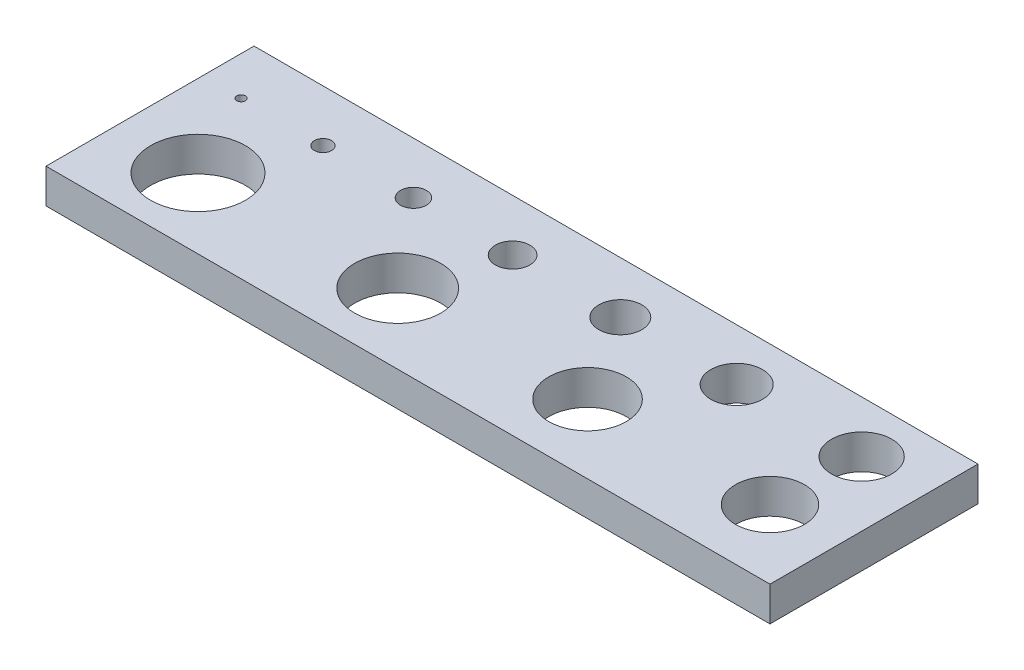
from build123d import *

# Parameters (mm, degrees)
SKETCH1_W           = 210
SKETCH1_H           = 60.3421622
SKETCH1_R           = 1.25
SKETCH1_R_2         = 2.5
SKETCH1_R_3         = 3.75
SKETCH1_R_4         = 5
SKETCH1_R_5         = 6.25
SKETCH1_R_6         = 7.5
SKETCH1_R_7         = 8.75
SKETCH1_R_8         = 10
SKETCH1_R_9         = 11.25
SKETCH1_R_10        = 12.5
SKETCH1_R_11        = 13.75
BOSS_EXTRUDE1_DEPTH = 10


with BuildPart() as part:
    # Sketch1 → Boss-Extrude1 (new body)
    with BuildSketch(Plane(origin=(0, 0, 0), x_dir=(1, 0, 0), z_dir=(0, 1, 0))):
        with Locations((93.75, -15.1710811)):
            Rectangle(SKETCH1_W, SKETCH1_H)
        Circle(SKETCH1_R, mode=Mode.SUBTRACT)
        with Locations((23.75, 0)):
            Circle(SKETCH1_R_2, mode=Mode.SUBTRACT)
        with Locations((50, 0)):
            Circle(SKETCH1_R_3, mode=Mode.SUBTRACT)
        with Locations((78.75, 0)):
            Circle(SKETCH1_R_4, mode=Mode.SUBTRACT)
        with Locations((110, 0)):
            Circle(SKETCH1_R_5, mode=Mode.SUBTRACT)
        with Locations((143.75, 0)):
            Circle(SKETCH1_R_6, mode=Mode.SUBTRACT)
        with Locations((180, 0)):
            Circle(SKETCH1_R_7, mode=Mode.SUBTRACT)
        with Locations((178.75, -25.3421622)):
            Circle(SKETCH1_R_8, mode=Mode.SUBTRACT)
        with Locations((125.831772041, -25.3421622)):
            Circle(SKETCH1_R_9, mode=Mode.SUBTRACT)
        with Locations((70.418227959, -25)):
            Circle(SKETCH1_R_10, mode=Mode.SUBTRACT)
        with Locations((12.5, -25)):
            Circle(SKETCH1_R_11, mode=Mode.SUBTRACT)
    extrude(amount=BOSS_EXTRUDE1_DEPTH)


solid = part.part
